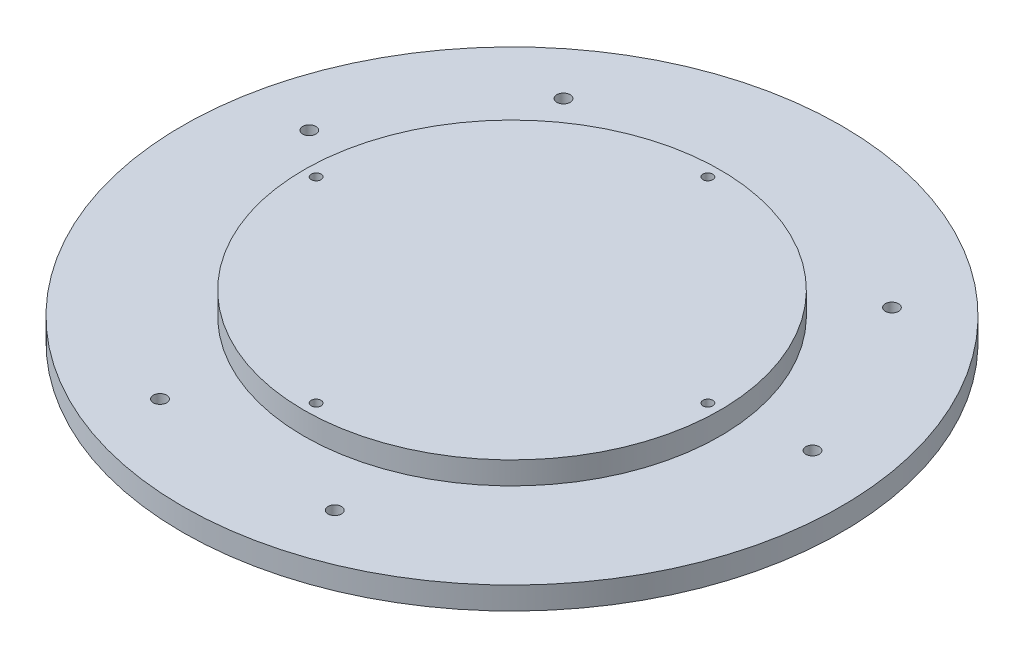
from build123d import *

# Parameters (mm, degrees)
ESQUISSE1_R                                = 84.1225
BOSS_EXTRU_1_DEPTH                         = 5.75
ESQUISSE2_R                                = 53.13
BOSS_EXTRU_2_DEPTH                         = 5.75
TROU_TARAUD_M31_D                          = 2.5
TROU_TARAUD_M31_DEPTH                      = 12.5
TROU_TARAUD_M31_TIP                        = 0.751075774
CHAMBRAGE_POUR_VIS_T_TE_HEXAGONALE_2_COUNT = 2
CHAMBRAGE_POUR_VIS_T_TE_HEXAGONALE_2_PITCH = 46.9428037
CHAMBRAGE_POUR_VIS_T_TE_HEXAGONALE_3_COUNT = 2
CHAMBRAGE_POUR_VIS_T_TE_HEXAGONALE_3_PITCH = 118.863351538
CHAMBRAGE_POUR_VIS_T_TE_HEXAGONALE_4_COUNT = 2
CHAMBRAGE_POUR_VIS_T_TE_HEXAGONALE_4_PITCH = 135.166416173
CHAMBRAGE_POUR_VIS_T_TE_HEXAGONALE_5_COUNT = 2
CHAMBRAGE_POUR_VIS_T_TE_HEXAGONALE_5_PITCH = 118.863351538
CHAMBRAGE_POUR_VIS_T_TE_HEXAGONALE_6_COUNT = 2
CHAMBRAGE_POUR_VIS_T_TE_HEXAGONALE_6_PITCH = 88.223612472


with BuildPart() as part:
    # Esquisse1 → Boss.-Extru.1 (new body)
    with BuildSketch(Plane(origin=(0, 0, 0), x_dir=(1, 0, 0), z_dir=(0, 1, 0))):
        Circle(ESQUISSE1_R)
    extrude(amount=-BOSS_EXTRU_1_DEPTH)

    # Esquisse2 → Boss.-Extru.2 (add)
    with BuildSketch(Plane(origin=(0, 0, 0), x_dir=(1, 0, 0), z_dir=(0, 1, 0))):
        Circle(ESQUISSE2_R)
    extrude(amount=BOSS_EXTRU_2_DEPTH)

    # Trou taraudé M31
    with Locations(Plane(origin=(0, -5.75, -50), x_dir=(0, 0, -1), z_dir=(0, -1, 0))):
        with Locations((0, 0), (-50, -50), (-100, 0), (-50, 50)):
            Hole(TROU_TARAUD_M31_D / 2, depth=TROU_TARAUD_M31_DEPTH)
            with Locations((0, 0, -(TROU_TARAUD_M31_DEPTH + TROU_TARAUD_M31_TIP / 2))):  # 118° drill point
                Cone(0, TROU_TARAUD_M31_D / 2, TROU_TARAUD_M31_TIP, mode=Mode.SUBTRACT)

    # Esquisse7 → Chambrage pour vis à tête hexagonale M31 (revolve, cut)
    with BuildSketch(Plane(origin=(-26.582568127, -5.75, 63.268205691), x_dir=(0, 0, -1), z_dir=(1, 0, 0))):
        Polygon((0, 0), (0, 11.5), (1.7, 11.5), (1.7, 2), (4.6755, 2), (4.6755, 0.025), (4.7005, 0), align=None)
    chambrage_pour_vis_t_te_hexagonale_m31 = revolve(axis=Axis((-26.582568127, -12.1, 63.268205691), (0, 1, 0)), mode=Mode.SUBTRACT)

    # Chambrage pour vis _ t_te hexagonale 2: Chambrage pour vis à tête hexagonale M31 ×2
    with Locations(*[Vector(0.998814611, 0, 0.048676196) * (i * CHAMBRAGE_POUR_VIS_T_TE_HEXAGONALE_2_PITCH) for i in range(1, CHAMBRAGE_POUR_VIS_T_TE_HEXAGONALE_2_COUNT)]):
        add(chambrage_pour_vis_t_te_hexagonale_m31, mode=Mode.SUBTRACT)

    # Chambrage pour vis _ t_te hexagonale 3: Chambrage pour vis à tête hexagonale M31 ×2
    with Locations(*[Vector(0.796424839, 0, -0.604737527) * (i * CHAMBRAGE_POUR_VIS_T_TE_HEXAGONALE_3_PITCH) for i in range(1, CHAMBRAGE_POUR_VIS_T_TE_HEXAGONALE_3_COUNT)]):
        add(chambrage_pour_vis_t_te_hexagonale_m31, mode=Mode.SUBTRACT)

    # Chambrage pour vis _ t_te hexagonale 4: Chambrage pour vis à tête hexagonale M31 ×2
    with Locations(*[Vector(0.541562128, 0, -0.840660729) * (i * CHAMBRAGE_POUR_VIS_T_TE_HEXAGONALE_4_PITCH) for i in range(1, CHAMBRAGE_POUR_VIS_T_TE_HEXAGONALE_4_COUNT)]):
        add(chambrage_pour_vis_t_te_hexagonale_m31, mode=Mode.SUBTRACT)

    # Chambrage pour vis _ t_te hexagonale 5: Chambrage pour vis à tête hexagonale M31 ×2
    with Locations(*[Vector(-0.125505642, 0, -0.992092906) * (i * CHAMBRAGE_POUR_VIS_T_TE_HEXAGONALE_5_PITCH) for i in range(1, CHAMBRAGE_POUR_VIS_T_TE_HEXAGONALE_5_COUNT)]):
        add(chambrage_pour_vis_t_te_hexagonale_m31, mode=Mode.SUBTRACT)

    # Chambrage pour vis _ t_te hexagonale 6: Chambrage pour vis à tête hexagonale M31 ×2
    with Locations(*[Vector(-0.457252483, 0, -0.889336925) * (i * CHAMBRAGE_POUR_VIS_T_TE_HEXAGONALE_6_PITCH) for i in range(1, CHAMBRAGE_POUR_VIS_T_TE_HEXAGONALE_6_COUNT)]):
        add(chambrage_pour_vis_t_te_hexagonale_m31, mode=Mode.SUBTRACT)


solid = part.part
